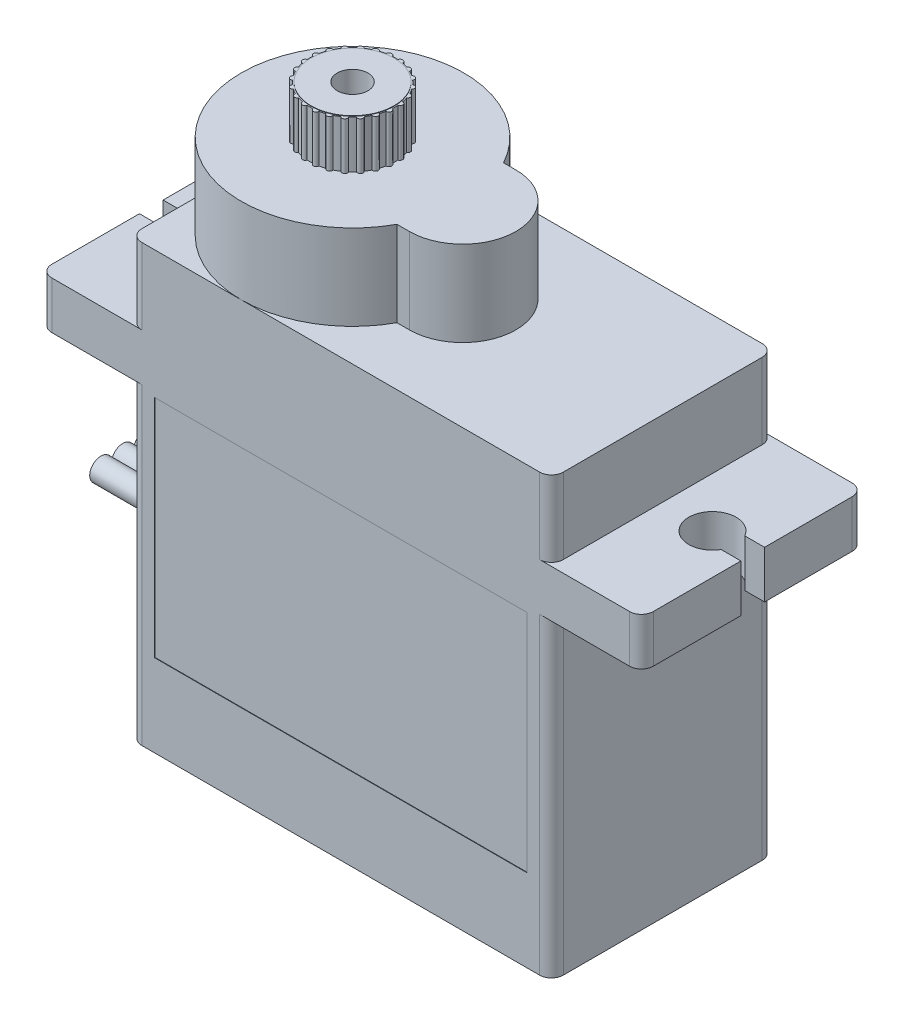
from build123d import *

# Parameters (mm, degrees)
SKETCH1_W               = 22.606
SKETCH1_H               = 11.938
BOSS_EXTRUDE1_DEPTH     = 23.368
SKETCH3_W               = 11.938
SKETCH3_H               = 2.54
BOSS_EXTRUDE2_DEPTH     = 16.129
BOSS_EXTRUDE3_DEPTH     = 4.572
CUT_EXTRUDE1_DEPTH      = 9.636
CUT_EXTRUDE1_DEPTH_BACK = 20.304
SKETCH6_R               = 2.413
SKETCH6_R_2             = 2.286
SKETCH6_R_3             = 0.8255
BOSS_EXTRUDE4_DEPTH     = 2.54
CUT_EXTRUDE2_DEPTH      = 2.54
SKETCH9_R               = 2.2225
SKETCH9_R_2             = 0.8255
BOSS_EXTRUDE5_DEPTH     = 0.0254
FILLET1_R               = 0.635
FILLET2_R               = 0.635
SKETCH10_R              = 0.98425
CUT_EXTRUDE3_DEPTH      = 2.54
SKETCH11_R              = 0.60325
BOSS_EXTRUDE7_DEPTH     = 6.35
SKETCH13_W              = 19.9898
SKETCH13_H              = 12.0904
CUT_EXTRUDE4_DEPTH      = 0.0254


with BuildPart() as part:
    # Sketch1 → Boss-Extrude1 (new body)
    with BuildSketch(Plane(origin=(0, 0, 0), x_dir=(1, 0, 0), z_dir=(0, 1, 0))):
        Rectangle(SKETCH1_W, SKETCH1_H)
    extrude(amount=BOSS_EXTRUDE1_DEPTH)

    # Sketch3 → Boss-Extrude2 (add, symmetric)
    with BuildSketch(Plane(origin=(0, 0, 0), x_dir=(0, 0, -1), z_dir=(1, 0, 0))):
        with Locations((0, 18.034)):
            Rectangle(SKETCH3_W, SKETCH3_H)
    extrude(amount=BOSS_EXTRUDE2_DEPTH, both=True)

    # Sketch4 → Boss-Extrude3 (add)
    with BuildSketch(Plane(origin=(0, 23.368, 0), x_dir=(1, 0, 0), z_dir=(0, 1, 0))):
        with BuildLine():
            Line((0.5715, 2.8575), (-0.093422289, 2.8575))
            ThreePointArc((-0.093422289, 2.8575), (-11.303, 0), (-0.093422289, -2.8575))
            Line((-0.093422289, -2.8575), (0.5715, -2.8575))
            ThreePointArc((0.5715, -2.8575), (3.429, 0), (0.5715, 2.8575))
        make_face()
    extrude(amount=BOSS_EXTRUDE3_DEPTH)

    # Sketch5 → Cut-Extrude1 (cut, two sides)
    with BuildSketch(Plane(origin=(0, 19.304, 0), x_dir=(1, 0, 0), z_dir=(0, 1, 0))) as cut_extrude1_sk:
        with BuildLine():
            ThreePointArc((-15.069852263, 0.635), (-12.7, 0), (-15.069852263, -0.635))
            Line((-15.069852263, -0.635), (-16.129, -0.635))
            Line((-16.129, -0.635), (-16.129, 0.635))
            Line((-16.129, 0.635), (-15.069852263, 0.635))
        make_face()
        with BuildLine():
            Line((16.129, -0.635), (16.129, 0.635))
            Line((16.129, 0.635), (15.069852263, 0.635))
            ThreePointArc((15.069852263, 0.635), (12.7, 0), (15.069852263, -0.635))
            Line((15.069852263, -0.635), (16.129, -0.635))
        make_face()
    extrude(amount=CUT_EXTRUDE1_DEPTH, mode=Mode.SUBTRACT)
    extrude(cut_extrude1_sk.sketch, amount=-CUT_EXTRUDE1_DEPTH_BACK, mode=Mode.SUBTRACT)

    # Sketch6 → Boss-Extrude4 (add)
    with BuildSketch(Plane(origin=(0, 27.94, 0), x_dir=(1, 0, 0), z_dir=(0, 1, 0))):
        with Locations((-5.334, 0)):
            Circle(SKETCH6_R)
        with Locations((-5.334, 0)):
            Circle(SKETCH6_R_2, mode=Mode.SUBTRACT)
        with Locations((-5.334, 0)):
            Circle(SKETCH6_R_2)
        with Locations((-5.334, 0)):
            Circle(SKETCH6_R_3, mode=Mode.SUBTRACT)
    extrude(amount=BOSS_EXTRUDE4_DEPTH)

    # Sketch8 → Cut-Extrude2 (cut)
    with BuildSketch(Plane(origin=(0, 30.48, 0), x_dir=(1, 0, 0), z_dir=(0, 1, 0))):
        with BuildLine():
            ThreePointArc((-6.841264533, 1.7187058), (-6.859086333, 1.823777663), (-6.802941328, 1.91436161))
            ThreePointArc((-6.802941328, 1.91436161), (-7.040248663, 1.706248663), (-7.24836161, 1.468941328))
            ThreePointArc((-7.24836161, 1.468941328), (-7.157777663, 1.525086333), (-7.0527058, 1.507264533))
            ThreePointArc((-7.0527058, 1.507264533), (-6.950446102, 1.616446102), (-6.841264533, 1.7187058))
        make_face()
        with BuildLine():
            ThreePointArc((-7.234739534, 1.270033553), (-7.279148669, 1.366912558), (-7.24836161, 1.468941328))
            ThreePointArc((-7.24836161, 1.468941328), (-7.423719299, 1.2065), (-7.563321312, 0.923415122))
            ThreePointArc((-7.563321312, 0.923415122), (-7.490355335, 1.001091883), (-7.384251087, 1.011071946))
            ThreePointArc((-7.384251087, 1.011071946), (-7.313734073, 1.143), (-7.234739534, 1.270033553))
        make_face()
        with BuildLine():
            ThreePointArc((-7.498682276, 0.734810618), (-7.566652339, 0.816894621), (-7.563321312, 0.923415122))
            ThreePointArc((-7.563321312, 0.923415122), (-7.664779019, 0.624530356), (-7.72635645, 0.314959702))
            ThreePointArc((-7.72635645, 0.314959702), (-7.675980953, 0.408874675), (-7.576075151, 0.445976476))
            ThreePointArc((-7.576075151, 0.445976476), (-7.542106439, 0.591660337), (-7.498682276, 0.734810618))
        make_face()
        with BuildLine():
            ThreePointArc((-7.615105499, 0.149511553), (-7.702004441, 0.211206665), (-7.72635645, 0.314959702))
            ThreePointArc((-7.72635645, 0.314959702), (-7.747, 0), (-7.72635645, -0.314959702))
            ThreePointArc((-7.72635645, -0.314959702), (-7.702004441, -0.211206665), (-7.615105499, -0.149511553))
            ThreePointArc((-7.615105499, -0.149511553), (-7.62, 0), (-7.615105499, 0.149511553))
        make_face()
        with BuildLine():
            ThreePointArc((-7.576075151, -0.445976476), (-7.675980953, -0.408874675), (-7.72635645, -0.314959702))
            ThreePointArc((-7.72635645, -0.314959702), (-7.664779019, -0.624530356), (-7.563321312, -0.923415122))
            ThreePointArc((-7.563321312, -0.923415122), (-7.566652339, -0.816894621), (-7.498682276, -0.734810618))
            ThreePointArc((-7.498682276, -0.734810618), (-7.542106439, -0.591660337), (-7.576075151, -0.445976476))
        make_face()
        with BuildLine():
            ThreePointArc((-7.384251087, -1.011071946), (-7.490355335, -1.001091883), (-7.563321312, -0.923415122))
            ThreePointArc((-7.563321312, -0.923415122), (-7.423719299, -1.2065), (-7.24836161, -1.468941328))
            ThreePointArc((-7.24836161, -1.468941328), (-7.279148669, -1.366912558), (-7.234739534, -1.270033553))
            ThreePointArc((-7.234739534, -1.270033553), (-7.313734073, -1.143), (-7.384251087, -1.011071946))
        make_face()
        with BuildLine():
            ThreePointArc((-7.0527058, -1.507264533), (-7.157777663, -1.525086333), (-7.24836161, -1.468941328))
            ThreePointArc((-7.24836161, -1.468941328), (-7.040248663, -1.706248663), (-6.802941328, -1.91436161))
            ThreePointArc((-6.802941328, -1.91436161), (-6.859086333, -1.823777663), (-6.841264533, -1.7187058))
            ThreePointArc((-6.841264533, -1.7187058), (-6.950446102, -1.616446102), (-7.0527058, -1.507264533))
        make_face()
        with BuildLine():
            ThreePointArc((-6.604033553, -1.900739534), (-6.700912558, -1.945148669), (-6.802941328, -1.91436161))
            ThreePointArc((-6.802941328, -1.91436161), (-6.5405, -2.089719299), (-6.257415122, -2.229321312))
            ThreePointArc((-6.257415122, -2.229321312), (-6.335091883, -2.156355335), (-6.345071946, -2.050251087))
            ThreePointArc((-6.345071946, -2.050251087), (-6.477, -1.979734073), (-6.604033553, -1.900739534))
        make_face()
        with BuildLine():
            ThreePointArc((-6.068810618, -2.164682276), (-6.150894621, -2.232652339), (-6.257415122, -2.229321312))
            ThreePointArc((-6.257415122, -2.229321312), (-5.958530356, -2.330779019), (-5.648959702, -2.39235645))
            ThreePointArc((-5.648959702, -2.39235645), (-5.742874675, -2.341980953), (-5.779976476, -2.242075151))
            ThreePointArc((-5.779976476, -2.242075151), (-5.925660337, -2.208106439), (-6.068810618, -2.164682276))
        make_face()
        with BuildLine():
            ThreePointArc((-5.648959702, -2.39235645), (-5.334, -2.413), (-5.019040298, -2.39235645))
            ThreePointArc((-5.019040298, -2.39235645), (-5.122793335, -2.368004441), (-5.184488447, -2.281105499))
            ThreePointArc((-5.184488447, -2.281105499), (-5.334, -2.286), (-5.483511553, -2.281105499))
            ThreePointArc((-5.483511553, -2.281105499), (-5.545206665, -2.368004441), (-5.648959702, -2.39235645))
        make_face()
        with BuildLine():
            ThreePointArc((-5.019040298, -2.39235645), (-4.709469644, -2.330779019), (-4.410584878, -2.229321312))
            ThreePointArc((-4.410584878, -2.229321312), (-4.517105379, -2.232652339), (-4.599189382, -2.164682276))
            ThreePointArc((-4.599189382, -2.164682276), (-4.742339663, -2.208106439), (-4.888023524, -2.242075151))
            ThreePointArc((-4.888023524, -2.242075151), (-4.925125325, -2.341980953), (-5.019040298, -2.39235645))
        make_face()
        with BuildLine():
            ThreePointArc((-4.410584878, -2.229321312), (-4.1275, -2.089719299), (-3.865058672, -1.91436161))
            ThreePointArc((-3.865058672, -1.91436161), (-3.967087442, -1.945148669), (-4.063966447, -1.900739534))
            ThreePointArc((-4.063966447, -1.900739534), (-4.191, -1.979734073), (-4.322928054, -2.050251087))
            ThreePointArc((-4.322928054, -2.050251087), (-4.332908117, -2.156355335), (-4.410584878, -2.229321312))
        make_face()
        with BuildLine():
            ThreePointArc((-3.865058672, -1.91436161), (-3.627751337, -1.706248663), (-3.41963839, -1.468941328))
            ThreePointArc((-3.41963839, -1.468941328), (-3.510222337, -1.525086333), (-3.6152942, -1.507264533))
            ThreePointArc((-3.6152942, -1.507264533), (-3.717553898, -1.616446102), (-3.826735467, -1.7187058))
            ThreePointArc((-3.826735467, -1.7187058), (-3.808913667, -1.823777663), (-3.865058672, -1.91436161))
        make_face()
        with BuildLine():
            ThreePointArc((-3.41963839, -1.468941328), (-3.244280701, -1.2065), (-3.104678688, -0.923415122))
            ThreePointArc((-3.104678688, -0.923415122), (-3.177644665, -1.001091883), (-3.283748913, -1.011071946))
            ThreePointArc((-3.283748913, -1.011071946), (-3.354265927, -1.143), (-3.433260466, -1.270033553))
            ThreePointArc((-3.433260466, -1.270033553), (-3.388851331, -1.366912558), (-3.41963839, -1.468941328))
        make_face()
        with BuildLine():
            ThreePointArc((-3.104678688, -0.923415122), (-3.003220981, -0.624530356), (-2.94164355, -0.314959702))
            ThreePointArc((-2.94164355, -0.314959702), (-2.992019047, -0.408874675), (-3.091924849, -0.445976476))
            ThreePointArc((-3.091924849, -0.445976476), (-3.125893561, -0.591660337), (-3.169317724, -0.734810618))
            ThreePointArc((-3.169317724, -0.734810618), (-3.101347661, -0.816894621), (-3.104678688, -0.923415122))
        make_face()
        with BuildLine():
            ThreePointArc((-2.921, 0), (-2.926166418, 0.157817751), (-2.94164355, 0.314959702))
            ThreePointArc((-2.94164355, 0.314959702), (-2.965995559, 0.211206665), (-3.052894501, 0.149511553))
            ThreePointArc((-3.052894501, 0.149511553), (-3.049223953, 0.074795823), (-3.048, 0))
            ThreePointArc((-3.048, 0), (-3.049223953, -0.074795823), (-3.052894501, -0.149511553))
            ThreePointArc((-3.052894501, -0.149511553), (-2.965995559, -0.211206665), (-2.94164355, -0.314959702))
            ThreePointArc((-2.94164355, -0.314959702), (-2.926166418, -0.157817751), (-2.921, 0))
        make_face()
        with BuildLine():
            ThreePointArc((-2.94164355, 0.314959702), (-3.003220981, 0.624530356), (-3.104678688, 0.923415122))
            ThreePointArc((-3.104678688, 0.923415122), (-3.101347661, 0.816894621), (-3.169317724, 0.734810618))
            ThreePointArc((-3.169317724, 0.734810618), (-3.125893561, 0.591660337), (-3.091924849, 0.445976476))
            ThreePointArc((-3.091924849, 0.445976476), (-2.992019047, 0.408874675), (-2.94164355, 0.314959702))
        make_face()
        with BuildLine():
            ThreePointArc((-3.104678688, 0.923415122), (-3.244280701, 1.2065), (-3.41963839, 1.468941328))
            ThreePointArc((-3.41963839, 1.468941328), (-3.388851331, 1.366912558), (-3.433260466, 1.270033553))
            ThreePointArc((-3.433260466, 1.270033553), (-3.354265927, 1.143), (-3.283748913, 1.011071946))
            ThreePointArc((-3.283748913, 1.011071946), (-3.177644665, 1.001091883), (-3.104678688, 0.923415122))
        make_face()
        with BuildLine():
            ThreePointArc((-3.41963839, 1.468941328), (-3.627751337, 1.706248663), (-3.865058672, 1.91436161))
            ThreePointArc((-3.865058672, 1.91436161), (-3.808913667, 1.823777663), (-3.826735467, 1.7187058))
            ThreePointArc((-3.826735467, 1.7187058), (-3.717553898, 1.616446102), (-3.6152942, 1.507264533))
            ThreePointArc((-3.6152942, 1.507264533), (-3.510222337, 1.525086333), (-3.41963839, 1.468941328))
        make_face()
        with BuildLine():
            ThreePointArc((-3.865058672, 1.91436161), (-4.1275, 2.089719299), (-4.410584878, 2.229321312))
            ThreePointArc((-4.410584878, 2.229321312), (-4.332908117, 2.156355335), (-4.322928054, 2.050251087))
            ThreePointArc((-4.322928054, 2.050251087), (-4.191, 1.979734073), (-4.063966447, 1.900739534))
            ThreePointArc((-4.063966447, 1.900739534), (-3.967087442, 1.945148669), (-3.865058672, 1.91436161))
        make_face()
        with BuildLine():
            ThreePointArc((-4.410584878, 2.229321312), (-4.709469644, 2.330779019), (-5.019040298, 2.39235645))
            ThreePointArc((-5.019040298, 2.39235645), (-4.925125325, 2.341980953), (-4.888023524, 2.242075151))
            ThreePointArc((-4.888023524, 2.242075151), (-4.742339663, 2.208106439), (-4.599189382, 2.164682276))
            ThreePointArc((-4.599189382, 2.164682276), (-4.517105379, 2.232652339), (-4.410584878, 2.229321312))
        make_face()
        with BuildLine():
            ThreePointArc((-5.184488447, 2.281105499), (-5.122793335, 2.368004441), (-5.019040298, 2.39235645))
            ThreePointArc((-5.019040298, 2.39235645), (-5.334, 2.413), (-5.648959702, 2.39235645))
            ThreePointArc((-5.648959702, 2.39235645), (-5.545206665, 2.368004441), (-5.483511553, 2.281105499))
            ThreePointArc((-5.483511553, 2.281105499), (-5.334, 2.286), (-5.184488447, 2.281105499))
        make_face()
        with BuildLine():
            ThreePointArc((-5.779976476, 2.242075151), (-5.742874675, 2.341980953), (-5.648959702, 2.39235645))
            ThreePointArc((-5.648959702, 2.39235645), (-5.958530356, 2.330779019), (-6.257415122, 2.229321312))
            ThreePointArc((-6.257415122, 2.229321312), (-6.150894621, 2.232652339), (-6.068810618, 2.164682276))
            ThreePointArc((-6.068810618, 2.164682276), (-5.925660337, 2.208106439), (-5.779976476, 2.242075151))
        make_face()
        with BuildLine():
            ThreePointArc((-6.345071946, 2.050251087), (-6.335091883, 2.156355335), (-6.257415122, 2.229321312))
            ThreePointArc((-6.257415122, 2.229321312), (-6.5405, 2.089719299), (-6.802941328, 1.91436161))
            ThreePointArc((-6.802941328, 1.91436161), (-6.700912558, 1.945148669), (-6.604033553, 1.900739534))
            ThreePointArc((-6.604033553, 1.900739534), (-6.477, 1.979734073), (-6.345071946, 2.050251087))
        make_face()
    extrude(amount=-CUT_EXTRUDE2_DEPTH, mode=Mode.SUBTRACT)

    # Sketch9 → Boss-Extrude5 (add)
    with BuildSketch(Plane(origin=(0, 30.48, 0), x_dir=(1, 0, 0), z_dir=(0, 1, 0))):
        with Locations((-5.334, 0)):
            Circle(SKETCH9_R)
        with Locations((-5.334, 0)):
            Circle(SKETCH9_R_2, mode=Mode.SUBTRACT)
    extrude(amount=BOSS_EXTRUDE5_DEPTH)

    # Fillet1
    fillet1_edges = [part.edges().sort_by_distance(p)[0] for p in [
        (11.303, 8.382, 5.969),
        (-11.303, 8.382, 5.969),
        (-11.303, 8.382, -5.969),
        (11.303, 8.382, -5.969),
        (11.303, 21.336, 5.969),
        (-11.303, 21.336, 5.969),
        (-11.303, 21.336, -5.969),
        (11.303, 21.336, -5.969),
    ]]
    fillet(fillet1_edges, radius=FILLET1_R)

    # Fillet2
    fillet2_edges = [part.edges().sort_by_distance(p)[0] for p in [
        (-16.129, 18.034, 5.969),
        (-16.129, 18.034, -5.969),
        (16.129, 18.034, 5.969),
        (16.129, 18.034, -5.969),
    ]]
    fillet(fillet2_edges, radius=FILLET2_R)

    # Sketch10 → Cut-Extrude3 (cut)
    with BuildSketch(Plane.XZ):
        with Locations((-10.16, 4.826)):
            Circle(SKETCH10_R)
        with Locations((-10.16, -4.826)):
            Circle(SKETCH10_R)
        with Locations((10.16, -4.826)):
            Circle(SKETCH10_R)
        with Locations((10.16, 4.826)):
            Circle(SKETCH10_R)
    extrude(amount=-CUT_EXTRUDE3_DEPTH, mode=Mode.SUBTRACT)

    # Sketch11 → Boss-Extrude7 (add)
    with BuildSketch(Plane.ZY.offset(11.303)):
        with Locations((0, 6.95325)):
            Circle(SKETCH11_R)
        with Locations((-1.17475, 6.95325)):
            Circle(SKETCH11_R)
        with Locations((1.17475, 6.95325)):
            Circle(SKETCH11_R)
    extrude(amount=BOSS_EXTRUDE7_DEPTH)

    # Sketch13 → Cut-Extrude4 (cut)
    with BuildSketch(Plane.XY.offset(5.969)):
        with Locations((0, 10.4648)):
            Rectangle(SKETCH13_W, SKETCH13_H)
    extrude(amount=-CUT_EXTRUDE4_DEPTH, mode=Mode.SUBTRACT)


solid = part.part
